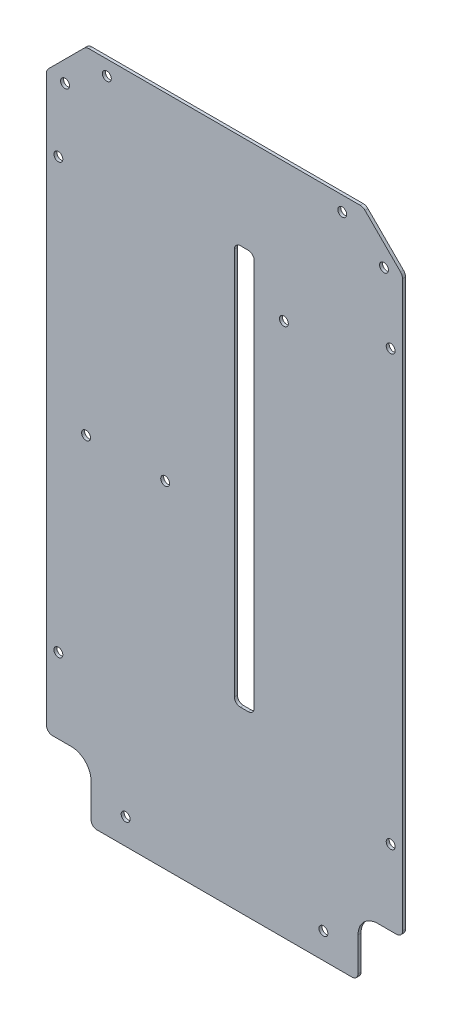
from build123d import *

# Parameters (mm, degrees)
ESQUISSE1_W                  = 180
ESQUISSE1_H                  = 340
BOSS_EXTRU_1_DEPTH           = 1.5
ESQUISSE2_R                  = 2.25
ENL_V_MAT_EXTRU_1_DEPTH      = 1
ENL_V_MAT_EXTRU_1_DEPTH_BACK = 2.5
ESQUISSE3_W                  = 22.5
ESQUISSE3_H                  = 30
ENL_V_MAT_EXTRU_2_DEPTH      = 1
ENL_V_MAT_EXTRU_2_DEPTH_BACK = 2.5
CONG_1_R                     = 10
CONG_2_R                     = 3
ESQUISSE4_W                  = 10
ESQUISSE4_H                  = 202
ENL_V_MAT_EXTRU_3_DEPTH      = 1
ENL_V_MAT_EXTRU_3_DEPTH_BACK = 2.5
CONG_3_R                     = 3
CHANFREIN1_SIZE              = 20
CHANFREIN2_SIZE              = 20
ESQUISSE5_R                  = 2.25
ENL_V_MAT_EXTRU_4_DEPTH      = 2.5
ESQUISSE6_R                  = 2.25
ENL_V_MAT_EXTRU_5_DEPTH      = 1
ENL_V_MAT_EXTRU_5_DEPTH_BACK = 2.5
CONG_4_R                     = 3.5


with BuildPart() as part:
    # Esquisse1 → Boss.-Extru.1 (new body)
    with BuildSketch(Plane.XY):
        with Locations((90, 170)):
            Rectangle(ESQUISSE1_W, ESQUISSE1_H)
    extrude(amount=BOSS_EXTRU_1_DEPTH)

    # Esquisse2 → Enlèv. mat.-Extru.1 (cut, two sides)
    with BuildSketch(Plane.XY.offset(1.5)) as enl_v_mat_extru_1_sk:
        with Locations((40, 13)):
            Circle(ESQUISSE2_R)
        with Locations((140, 13)):
            Circle(ESQUISSE2_R)
    extrude(amount=ENL_V_MAT_EXTRU_1_DEPTH, mode=Mode.SUBTRACT)
    extrude(enl_v_mat_extru_1_sk.sketch, amount=-ENL_V_MAT_EXTRU_1_DEPTH_BACK, mode=Mode.SUBTRACT)

    # Esquisse3 → Enlèv. mat.-Extru.2 (cut, two sides)
    with BuildSketch(Plane.XY.offset(1.5)) as enl_v_mat_extru_2_sk:
        with Locations((11.25, 15)):
            Rectangle(ESQUISSE3_W, ESQUISSE3_H)
        with Locations((168.75, 15)):
            Rectangle(ESQUISSE3_W, ESQUISSE3_H)
    extrude(amount=ENL_V_MAT_EXTRU_2_DEPTH, mode=Mode.SUBTRACT)
    extrude(enl_v_mat_extru_2_sk.sketch, amount=-ENL_V_MAT_EXTRU_2_DEPTH_BACK, mode=Mode.SUBTRACT)

    # Congé1
    cong_1_edges = [part.edges().sort_by_distance(p)[0] for p in [
        (22.5, 30, 0.75),
        (157.5, 30, 0.75),
    ]]
    fillet(cong_1_edges, radius=CONG_1_R)

    # Congé2
    cong_2_edges = [part.edges().sort_by_distance(p)[0] for p in [
        (0, 30, 0.75),
        (22.5, 0, 0.75),
        (180, 30, 0.75),
        (157.5, 0, 0.75),
    ]]
    fillet(cong_2_edges, radius=CONG_2_R)

    # Esquisse4 → Enlèv. mat.-Extru.3 (cut, two sides)
    with BuildSketch(Plane.XY.offset(1.5)) as enl_v_mat_extru_3_sk:
        with Locations((100, 191)):
            Rectangle(ESQUISSE4_W, ESQUISSE4_H)
    extrude(amount=ENL_V_MAT_EXTRU_3_DEPTH, mode=Mode.SUBTRACT)
    extrude(enl_v_mat_extru_3_sk.sketch, amount=-ENL_V_MAT_EXTRU_3_DEPTH_BACK, mode=Mode.SUBTRACT)

    # Congé3
    cong_3_edges = [part.edges().sort_by_distance(p)[0] for p in [
        (95, 90, 0.75),
        (95, 292, 0.75),
        (105, 292, 0.75),
        (105, 90, 0.75),
    ]]
    fillet(cong_3_edges, radius=CONG_3_R)

    # Chanfrein1
    chanfrein1_edges = [part.edges().sort_by_distance(p)[0] for p in [
        (180, 340, 0.75),
    ]]
    chamfer(chanfrein1_edges, length=CHANFREIN1_SIZE)

    # Chanfrein2
    chanfrein2_edges = [part.edges().sort_by_distance(p)[0] for p in [
        (0, 340, 0.75),
    ]]
    chamfer(chanfrein2_edges, length=CHANFREIN2_SIZE)

    # Esquisse5 → Enlèv. mat.-Extru.4 (cut, through all)
    with BuildSketch(Plane.XY.offset(1.5)):
        with Locations((120, 270)):
            Circle(ESQUISSE5_R)
    extrude(amount=-ENL_V_MAT_EXTRU_4_DEPTH, mode=Mode.SUBTRACT)

    # Esquisse6 → Enlèv. mat.-Extru.5 (cut, two sides)
    with BuildSketch(Plane.XY.offset(1.5)) as enl_v_mat_extru_5_sk:
        with Locations((6, 285)):
            Circle(ESQUISSE6_R)
        with Locations((6, 68)):
            Circle(ESQUISSE6_R)
        with Locations((174, 68)):
            Circle(ESQUISSE6_R)
        with Locations((174, 285)):
            Circle(ESQUISSE6_R)
        with Locations((20, 170)):
            Circle(ESQUISSE6_R)
        with Locations((60, 170)):
            Circle(ESQUISSE6_R)
        with Locations((149.5, 332.5)):
            Circle(ESQUISSE6_R)
        with Locations((170.630835149, 318.762563133)):
            Circle(ESQUISSE6_R)
        with Locations((9.369164851, 318.762563133)):
            Circle(ESQUISSE6_R)
        with Locations((30.5, 332.5)):
            Circle(ESQUISSE6_R)
    extrude(amount=ENL_V_MAT_EXTRU_5_DEPTH, mode=Mode.SUBTRACT)
    extrude(enl_v_mat_extru_5_sk.sketch, amount=-ENL_V_MAT_EXTRU_5_DEPTH_BACK, mode=Mode.SUBTRACT)

    # Congé4
    cong_4_edges = [part.edges().sort_by_distance(p)[0] for p in [
        (160, 340, 0.75),
        (180, 320, 0.75),
        (0, 320, 0.75),
        (20, 340, 0.75),
    ]]
    fillet(cong_4_edges, radius=CONG_4_R)


solid = part.part
